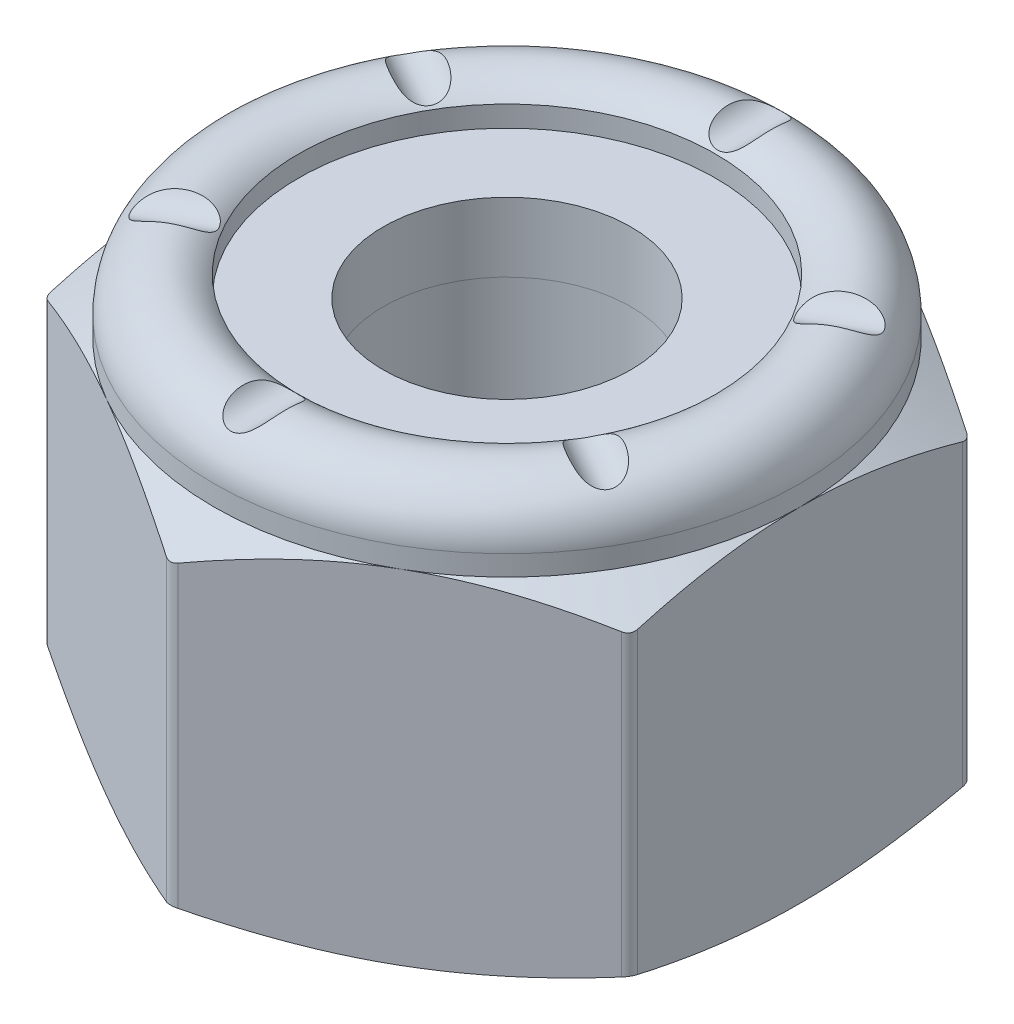
from build123d import *

# Parameters (mm, degrees)
SKETCH2_R                = 2.350110803
BOSS_EXTRUDE1_DEPTH      = 3.96875
BOSS_EXTRUDE1_DEPTH_BACK = 3.96875
FILLET1_R                = 0.22225
SKETCH11_W               = 1.603069599
SKETCH11_H               = 0.469528214
CIRPATTERN1_COUNT        = 6
SKETCH4_W                = 1.603069598
SKETCH4_H                = 1.31245674


with BuildPart() as part:
    # Sketch2 → Boss-Extrude1 (new body, two sides)
    with BuildSketch(Plane(origin=(0, 0, 0), x_dir=(1, 0, 0), z_dir=(0, 1, 0))) as boss_extrude1_sk:
        Polygon((0, 6.415804866), (-5.55625, 3.207902433), (-5.55625, -3.207902433), (0, -6.415804866), (5.55625, -3.207902433), (5.55625, 3.207902433), align=None)
        Circle(SKETCH2_R, mode=Mode.SUBTRACT)
    extrude(amount=BOSS_EXTRUDE1_DEPTH)
    extrude(boss_extrude1_sk.sketch, amount=-BOSS_EXTRUDE1_DEPTH_BACK)

    # Fillet1
    fillet1_edges = [part.edges().sort_by_distance(p)[0] for p in [
        (5.55625, 0, -3.207902433),
        (5.55625, 0, 3.207902433),
        (0, 0, 6.415804866),
        (-5.55625, 0, 3.207902433),
        (-5.55625, 0, -3.207902433),
        (0, 0, -6.415804866),
    ]]
    fillet(fillet1_edges, radius=FILLET1_R)

    # Sketch3 → Cut-Revolve2 (revolve, cut)
    with BuildSketch(Plane(origin=(0, 0, 0), x_dir=(0, 0, -1), z_dir=(1, 0, 0))):
        with BuildLine():
            Line((6.415804866, 2.645833333), (6.415804866, 4.96875))
            Line((6.415804866, 4.96875), (2.350110803, 4.96875))
            Line((2.350110803, 4.96875), (2.350110803, 1.984375))
            Line((2.350110803, 1.984375), (3.953180401, 1.984375))
            Line((3.953180401, 1.984375), (3.953180401, 3.69370674))
            ThreePointArc((3.953180401, 3.69370674), (4.976554908, 3.897268586), (5.55625, 3.029693571))
            Line((5.55625, 3.029693571), (5.55625, 2.645833333))
            Line((5.55625, 2.645833333), (6.415804866, 2.14137944))
            Line((6.415804866, 2.14137944), (6.415804866, 2.645833333))
        make_face()
        Polygon((5.334, -3.96875), (6.415804866, -3.464296106), (6.415804866, -3.96875), align=None)
        Polygon((2.350110803, -3.96875), (2.350110803, -3.33375), (2.985110803, -3.96875), align=None)
    revolve(axis=Axis((0, -3.96875, 0), (0, 1, 0)), mode=Mode.SUBTRACT)

    # Sketch11 → Cut-Revolve5 (revolve, cut)
    with BuildSketch(Plane(origin=(0, 0, 0), x_dir=(0, 0, -1), z_dir=(1, 0, 0))):
        with Locations((4.754715201, 3.96875)):
            Rectangle(SKETCH11_W, SKETCH11_H)
    cut_revolve5 = revolve(axis=Axis((0, 4.203514107, -3.953180401), (0, 0, -1)), mode=Mode.SUBTRACT)

    # CirPattern1: Cut-Revolve5 ×6 about axis
    cirpattern1_axis = Axis((0, -3.96875, 0), (0, 1, 0))
    for i in range(1, CIRPATTERN1_COUNT):
        add(cut_revolve5.rotate(cirpattern1_axis, i * 360 / CIRPATTERN1_COUNT), mode=Mode.SUBTRACT)


with BuildPart() as body_2:
    # Sketch4 → Revolve1 (revolve)
    with BuildSketch(Plane(origin=(0, 0, 0), x_dir=(0, 0, -1), z_dir=(1, 0, 0))):
        with Locations((-3.151645602, 2.64060337)):
            Rectangle(SKETCH4_W, SKETCH4_H)
    revolve(axis=Axis((0, -3.96875, 0), (0, 1, 0)))


solid = Compound([part.part, body_2.part])
